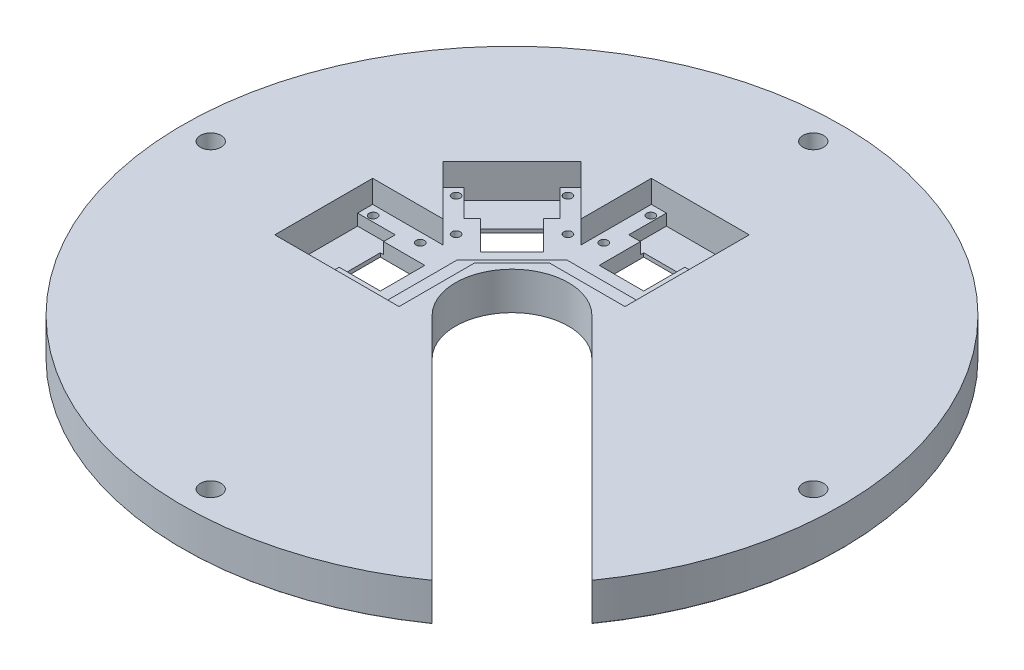
from build123d import *

# Parameters (mm, degrees)
SKETCH1_R                              = 87.5
BOSS_EXTRUDE1_DEPTH                    = 10
SKETCH2_R                              = 7.5
BOSS_EXTRUDE2_DEPTH                    = 80
CBORE_FOR_M5_HEX_HEAD_BOLT1_AT_2_COUNT = 2
CBORE_FOR_M5_HEX_HEAD_BOLT1_AT_2_PITCH = 113.13708499
CBORE_FOR_M5_HEX_HEAD_BOLT1_AT_3_COUNT = 2
CBORE_FOR_M5_HEX_HEAD_BOLT1_AT_3_PITCH = 160
CBORE_FOR_M5_HEX_HEAD_BOLT1_AT_4_COUNT = 2
CBORE_FOR_M5_HEX_HEAD_BOLT1_AT_4_PITCH = 113.13708499
SKETCH5_R                              = 87.5
CUT_EXTRUDE1_DEPTH                     = 80
FILLET1_R                              = 0.1
CUT_EXTRUDE2_DEPTH                     = 10
CUT_EXTRUDE3_DEPTH                     = 6
CUT_EXTRUDE4_DEPTH                     = 6
CUT_EXTRUDE5_DEPTH                     = 3
SKETCH11_R                             = 1.1
CUT_EXTRUDE6_DEPTH                     = 10
CUT_EXTRUDE7_DEPTH                     = 5
CIRPATTERN1_COUNT                      = 2
CIRPATTERN1_ANGLE                      = 45
CIRPATTERN1_THE_OTHER_WAY_COUNT        = 2
CIRPATTERN1_THE_OTHER_WAY_ANGLE        = 45


with BuildPart() as part:
    # Sketch1 → Boss-Extrude1 (new body)
    with BuildSketch(Plane(origin=(0, 0, 0), x_dir=(1, 0, 0), z_dir=(0, 1, 0))):
        Circle(SKETCH1_R)
    extrude(amount=BOSS_EXTRUDE1_DEPTH)

    # Sketch2 → Boss-Extrude2 (add)
    with BuildSketch(Plane(origin=(0, 10, 0), x_dir=(1, 0, 0), z_dir=(0, 1, 0))):
        with Locations((0, -80)):
            Circle(SKETCH2_R)
        with Locations((-80, 0)):
            Circle(SKETCH2_R)
        with Locations((0, 80)):
            Circle(SKETCH2_R)
        with Locations((80, 0)):
            Circle(SKETCH2_R)
    extrude(amount=BOSS_EXTRUDE2_DEPTH)

    # Sketch4 → CBORE for M5 Hex Head Bolt1 (revolve, cut)
    with BuildSketch(Plane(origin=(80, 0, 0), x_dir=(0, 0, -1), z_dir=(1, 0, 0))):
        Polygon((0, 0), (0, 21.652366702), (2.75, 20), (2.75, 3.58), (6.12, 3.58), (6.12, 0.025), (6.145, 0), align=None)
    cbore_for_m5_hex_head_bolt1 = revolve(axis=Axis((80, -6.35, 0), (0, 1, 0)), mode=Mode.SUBTRACT)

    # CBORE for M5 Hex Head Bolt1 at 2: CBORE for M5 Hex Head Bolt1 ×2
    with Locations(*[Vector(-0.707106781, 0, -0.707106781) * (i * CBORE_FOR_M5_HEX_HEAD_BOLT1_AT_2_PITCH) for i in range(1, CBORE_FOR_M5_HEX_HEAD_BOLT1_AT_2_COUNT)]):
        add(cbore_for_m5_hex_head_bolt1, mode=Mode.SUBTRACT)

    # CBORE for M5 Hex Head Bolt1 at 3: CBORE for M5 Hex Head Bolt1 ×2
    with Locations(*[(-i * CBORE_FOR_M5_HEX_HEAD_BOLT1_AT_3_PITCH, 0, 0) for i in range(1, CBORE_FOR_M5_HEX_HEAD_BOLT1_AT_3_COUNT)]):
        add(cbore_for_m5_hex_head_bolt1, mode=Mode.SUBTRACT)

    # CBORE for M5 Hex Head Bolt1 at 4: CBORE for M5 Hex Head Bolt1 ×2
    with Locations(*[Vector(-0.707106781, 0, 0.707106781) * (i * CBORE_FOR_M5_HEX_HEAD_BOLT1_AT_4_PITCH) for i in range(1, CBORE_FOR_M5_HEX_HEAD_BOLT1_AT_4_COUNT)]):
        add(cbore_for_m5_hex_head_bolt1, mode=Mode.SUBTRACT)

    # Sketch5 → Cut-Extrude1 (cut)
    with BuildSketch(Plane(origin=(0, 10, 0), x_dir=(1, 0, 0), z_dir=(0, 1, 0))):
        Circle(SKETCH5_R)
    extrude(amount=CUT_EXTRUDE1_DEPTH, mode=Mode.SUBTRACT)

    # Fillet1
    fillet1_edges = [part.edges().sort_by_distance(p)[0] for p in [
        (-87.5, 0, 0),
    ]]
    fillet(fillet1_edges, radius=FILLET1_R)

    # Sketch6 → Cut-Extrude2 (cut)
    with BuildSketch(Plane(origin=(0, 10, 0), x_dir=(1, 0, 0), z_dir=(0, 1, 0))):
        with BuildLine():
            Line((10.606601718, 10.606601718), (71.562528419, -50.349324983))
            ThreePointArc((71.562528419, -50.349324983), (61.871843354, -61.871843354), (50.349324983, -71.562528419))
            Line((50.349324983, -71.562528419), (-10.606601718, -10.606601718))
            ThreePointArc((-10.606601718, -10.606601718), (-10.606601718, 10.606601718), (10.606601718, 10.606601718))
        make_face()
    extrude(amount=-CUT_EXTRUDE2_DEPTH, mode=Mode.SUBTRACT)

    # Sketch7 → Cut-Extrude3 (cut)
    with BuildSketch(Plane(origin=(0, 10, 0), x_dir=(1, 0, 0), z_dir=(0, 1, 0))):
        Polygon((-8.485281374, 26.870057685), (-26.870057685, 8.485281374), (-44.547727215, 26.162950904), (-26.162950904, 44.547727215), align=None)
    cut_extrude3 = extrude(amount=-CUT_EXTRUDE3_DEPTH, mode=Mode.SUBTRACT)

    # Sketch8 → Cut-Extrude4 (cut)
    with BuildSketch(Plane.XZ):
        Polygon((-24.721867284, -16.378007266), (-16.378007266, -24.721867284), (-24.721867284, -33.065727302), (-33.065727302, -24.721867284), align=None)
    cut_extrude4 = extrude(amount=-CUT_EXTRUDE4_DEPTH, mode=Mode.SUBTRACT)

    # Sketch10 → Cut-Extrude5 (cut)
    with BuildSketch(Plane(origin=(0, 4, 0), x_dir=(1, 0, 0), z_dir=(0, 1, 0))):
        Polygon((-41.71930009, 28.991378029), (-28.991378029, 41.71930009), (-21.920310217, 34.648232278), (-34.648232278, 21.920310217), align=None)
    cut_extrude5 = extrude(amount=-CUT_EXTRUDE5_DEPTH, mode=Mode.SUBTRACT)

    # Sketch11 → Cut-Extrude6 (cut)
    with BuildSketch(Plane(origin=(0, 4, 0), x_dir=(1, 0, 0), z_dir=(0, 1, 0))):
        with Locations((-26.065370168, 40.914612573)):
            Circle(SKETCH11_R)
        with Locations((-40.914612573, 26.065370168)):
            Circle(SKETCH11_R)
        with Locations((-32.075777808, 17.226535403)):
            Circle(SKETCH11_R)
        with Locations((-17.226535403, 32.075777808)):
            Circle(SKETCH11_R)
    cut_extrude6 = extrude(amount=-CUT_EXTRUDE6_DEPTH, mode=Mode.SUBTRACT)

    # Sketch12 → Cut-Extrude7 (cut)
    with BuildSketch(Plane(origin=(0, 10, 0), x_dir=(1, 0, 0), z_dir=(0, 1, 0))):
        Polygon((-26.870057685, 8.485281374), (-8.485281374, 26.870057685), (-2.828427125, 21.213203436), (-21.213203436, 2.828427125), align=None)
    cut_extrude7 = extrude(amount=-CUT_EXTRUDE7_DEPTH, mode=Mode.SUBTRACT)

    # CirPattern1: Cut-Extrude3, Cut-Extrude4, Cut-Extrude5, Cut-Extrude6, Cut-Extrude7 ×2 about axis
    cirpattern1_axis = Axis((0, 0, 0), (0, 1, 0))
    for i in range(1, CIRPATTERN1_COUNT):
        add(cut_extrude3.rotate(cirpattern1_axis, i * CIRPATTERN1_ANGLE / (CIRPATTERN1_COUNT - 1)), mode=Mode.SUBTRACT)
        add(cut_extrude4.rotate(cirpattern1_axis, i * CIRPATTERN1_ANGLE / (CIRPATTERN1_COUNT - 1)), mode=Mode.SUBTRACT)
        add(cut_extrude5.rotate(cirpattern1_axis, i * CIRPATTERN1_ANGLE / (CIRPATTERN1_COUNT - 1)), mode=Mode.SUBTRACT)
        add(cut_extrude6.rotate(cirpattern1_axis, i * CIRPATTERN1_ANGLE / (CIRPATTERN1_COUNT - 1)), mode=Mode.SUBTRACT)
        add(cut_extrude7.rotate(cirpattern1_axis, i * CIRPATTERN1_ANGLE / (CIRPATTERN1_COUNT - 1)), mode=Mode.SUBTRACT)

    # CirPattern1 the other way: Cut-Extrude3, Cut-Extrude4, Cut-Extrude5, Cut-Extrude6, Cut-Extrude7 ×2 about axis
    cirpattern1_the_other_way_axis = Axis((0, 0, 0), (0, -1, 0))
    for i in range(1, CIRPATTERN1_THE_OTHER_WAY_COUNT):
        add(cut_extrude3.rotate(cirpattern1_the_other_way_axis, i * CIRPATTERN1_THE_OTHER_WAY_ANGLE / (CIRPATTERN1_THE_OTHER_WAY_COUNT - 1)), mode=Mode.SUBTRACT)
        add(cut_extrude4.rotate(cirpattern1_the_other_way_axis, i * CIRPATTERN1_THE_OTHER_WAY_ANGLE / (CIRPATTERN1_THE_OTHER_WAY_COUNT - 1)), mode=Mode.SUBTRACT)
        add(cut_extrude5.rotate(cirpattern1_the_other_way_axis, i * CIRPATTERN1_THE_OTHER_WAY_ANGLE / (CIRPATTERN1_THE_OTHER_WAY_COUNT - 1)), mode=Mode.SUBTRACT)
        add(cut_extrude6.rotate(cirpattern1_the_other_way_axis, i * CIRPATTERN1_THE_OTHER_WAY_ANGLE / (CIRPATTERN1_THE_OTHER_WAY_COUNT - 1)), mode=Mode.SUBTRACT)
        add(cut_extrude7.rotate(cirpattern1_the_other_way_axis, i * CIRPATTERN1_THE_OTHER_WAY_ANGLE / (CIRPATTERN1_THE_OTHER_WAY_COUNT - 1)), mode=Mode.SUBTRACT)


solid = part.part
